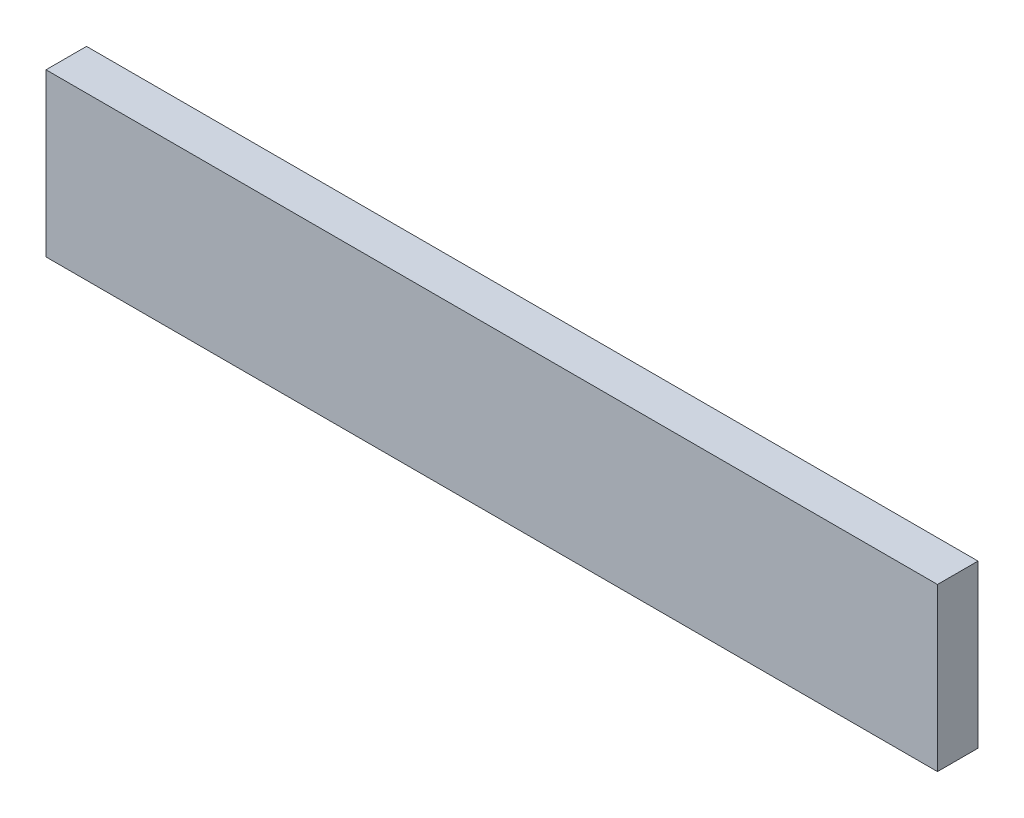
from build123d import *

# Parameters (mm, degrees)
SKETCH1_W           = 69.85
SKETCH1_H           = 12.7
BOSS_EXTRUDE1_DEPTH = 3.175


with BuildPart() as part:
    # Sketch1 → Boss-Extrude1 (new body)
    with BuildSketch(Plane.XY):
        with Locations((34.925, 6.35)):
            Rectangle(SKETCH1_W, SKETCH1_H)
    extrude(amount=BOSS_EXTRUDE1_DEPTH)


solid = part.part
